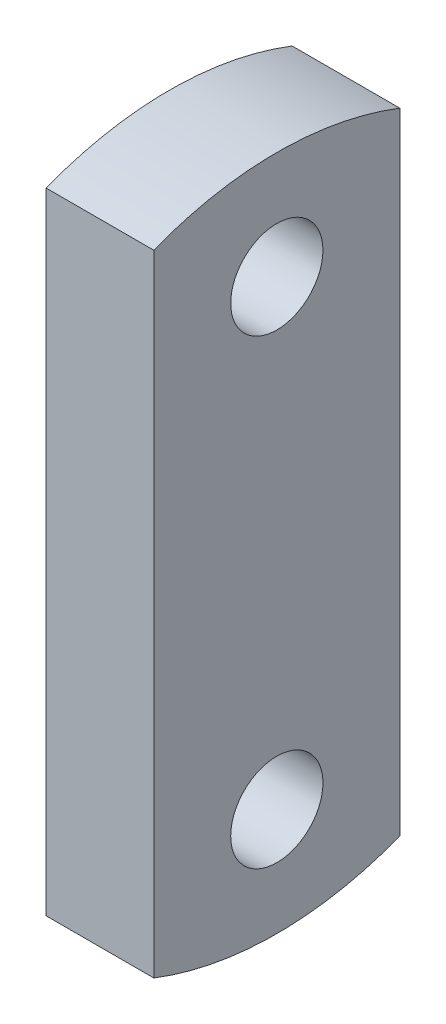
from build123d import *

# Parameters (mm, degrees)
SKETCH1_R           = 15
BOSS_EXTRUDE1_DEPTH = 35


with BuildPart() as part:
    # Sketch1 → Boss-Extrude1 (new body)
    with BuildSketch(Plane(origin=(0, 0, 0), x_dir=(0, 0, -1), z_dir=(1, 0, 0))):
        with BuildLine():
            Line((40, -102.46950766), (40, 102.46950766))
            ThreePointArc((40, 102.46950766), (0, 110), (-40, 102.46950766))
            Line((-40, 102.46950766), (-40, -102.46950766))
            ThreePointArc((-40, -102.46950766), (0, -110), (40, -102.46950766))
        make_face()
        with Locations((0, 75)):
            Circle(SKETCH1_R, mode=Mode.SUBTRACT)
        with Locations((0, -75)):
            Circle(SKETCH1_R, mode=Mode.SUBTRACT)
    extrude(amount=BOSS_EXTRUDE1_DEPTH)


solid = part.part
